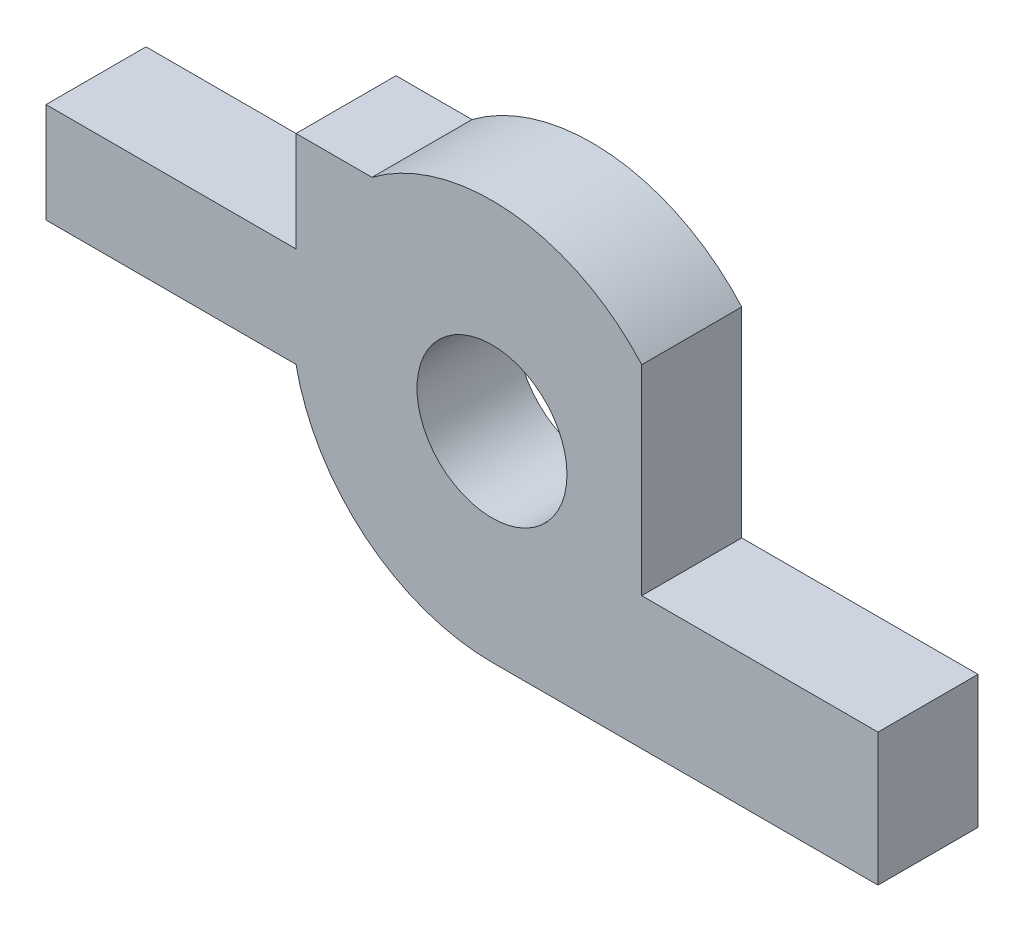
from build123d import *

# Parameters (mm, degrees)
SKETCH1_R           = 1.5
BOSS_EXTRUDE1_DEPTH = 2


with BuildPart() as part:
    # Sketch1 → Boss-Extrude1 (new body)
    with BuildSketch(Plane.XY):
        with BuildLine():
            Line((7.72, -4), (0, -4))
            ThreePointArc((0, -4), (-2.529822128, -3.098386677), (-3.919183588, -0.8))
            Line((-3.919183588, -0.8), (-8.919183588, -0.8))
            Line((-8.919183588, -0.8), (-8.919183588, 1.2))
            Line((-8.919183588, 1.2), (-3.919183588, 1.2))
            Line((-3.919183588, 1.2), (-3.919183588, 3.2))
            Line((-3.919183588, 3.2), (-2.4, 3.2))
            ThreePointArc((-2.4, 3.2), (0.404610957, 3.979483631), (2.994944065, 2.651473185))
            Line((2.994944065, 2.651473185), (2.994944065, -1.348526815))
            Line((2.994944065, -1.348526815), (7.72, -1.348526815))
            Line((7.72, -1.348526815), (7.72, -4))
        make_face()
        Circle(SKETCH1_R, mode=Mode.SUBTRACT)
    extrude(amount=BOSS_EXTRUDE1_DEPTH)


solid = part.part
